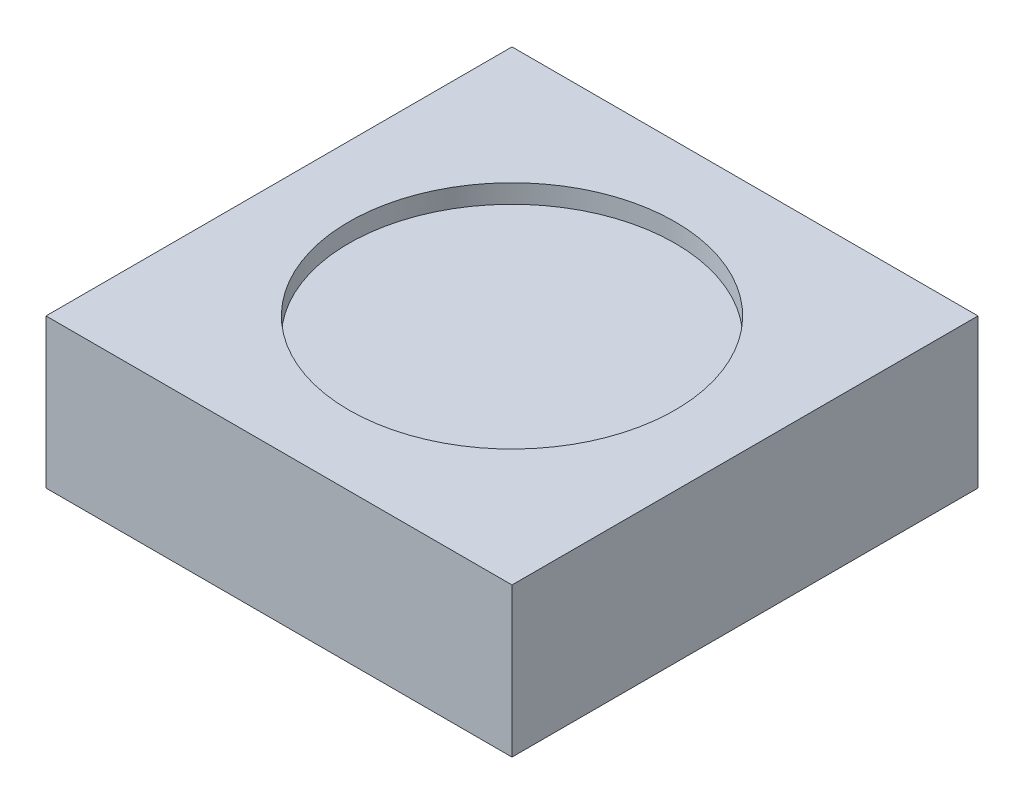
from build123d import *

# Parameters (mm, degrees)
SKETCH1_W           = 5
SKETCH1_H           = 5
BOSS_EXTRUDE1_DEPTH = 1.6
SKETCH2_R           = 1.75
CUT_EXTRUDE1_DEPTH  = 0.2


with BuildPart() as part:
    # Sketch1 → Boss-Extrude1 (new body)
    with BuildSketch(Plane(origin=(0, 0, 0), x_dir=(1, 0, 0), z_dir=(0, 1, 0))):
        Rectangle(SKETCH1_W, SKETCH1_H)
    extrude(amount=BOSS_EXTRUDE1_DEPTH)

    # Sketch2 → Cut-Extrude1 (cut)
    with BuildSketch(Plane(origin=(0, 1.6, 0), x_dir=(1, 0, 0), z_dir=(0, 1, 0))):
        Circle(SKETCH2_R)
    extrude(amount=-CUT_EXTRUDE1_DEPTH, mode=Mode.SUBTRACT)


solid = part.part
